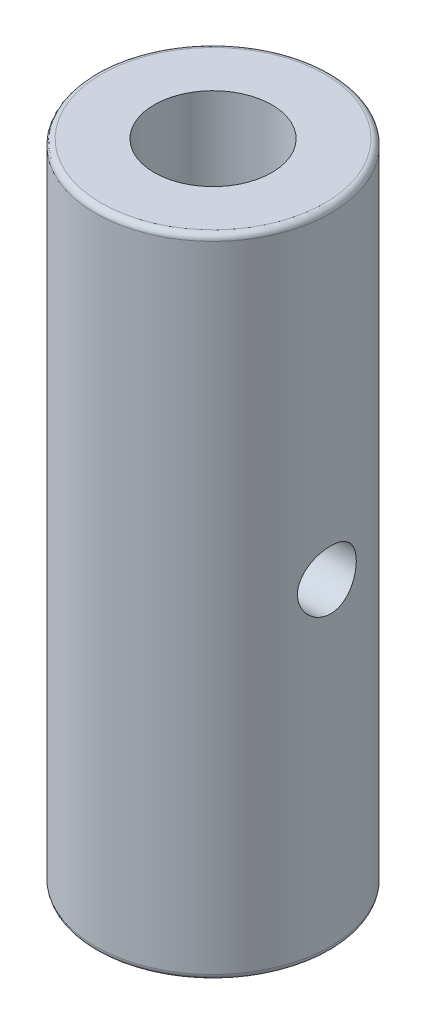
from build123d import *

# Parameters (mm, degrees)
SKETCH_1_R               = 20
SKETCH_1_R_2             = 10
EXTRUDE_1_DEPTH          = 110
SKETCH_2_R               = 5
CUT_EXTRUDE_1_DEPTH      = 21
CUT_EXTRUDE_1_DEPTH_BACK = 21
FILLET_1_R               = 1


with BuildPart() as part:
    # 草图1 → 凸台-拉伸1 (new body)
    with BuildSketch(Plane(origin=(0, 0, 0), x_dir=(1, 0, 0), z_dir=(0, 1, 0))):
        Circle(SKETCH_1_R)
        Circle(SKETCH_1_R_2, mode=Mode.SUBTRACT)
    extrude(amount=EXTRUDE_1_DEPTH)

    # 草图2 → 切除-拉伸1 (cut, two sides)
    with BuildSketch(Plane(origin=(0, 0, 0), x_dir=(0, 0, -1), z_dir=(1, 0, 0))) as cut_extrude_1_sk:
        with Locations((0, 55)):
            Circle(SKETCH_2_R)
    extrude(amount=CUT_EXTRUDE_1_DEPTH, mode=Mode.SUBTRACT)
    extrude(cut_extrude_1_sk.sketch, amount=-CUT_EXTRUDE_1_DEPTH_BACK, mode=Mode.SUBTRACT)

    # 圆角1
    fillet_1_edges = [part.edges().sort_by_distance(p)[0] for p in [
        (-20, 0, 0),
        (-20, 110, 0),
    ]]
    fillet(fillet_1_edges, radius=FILLET_1_R)


solid = part.part
